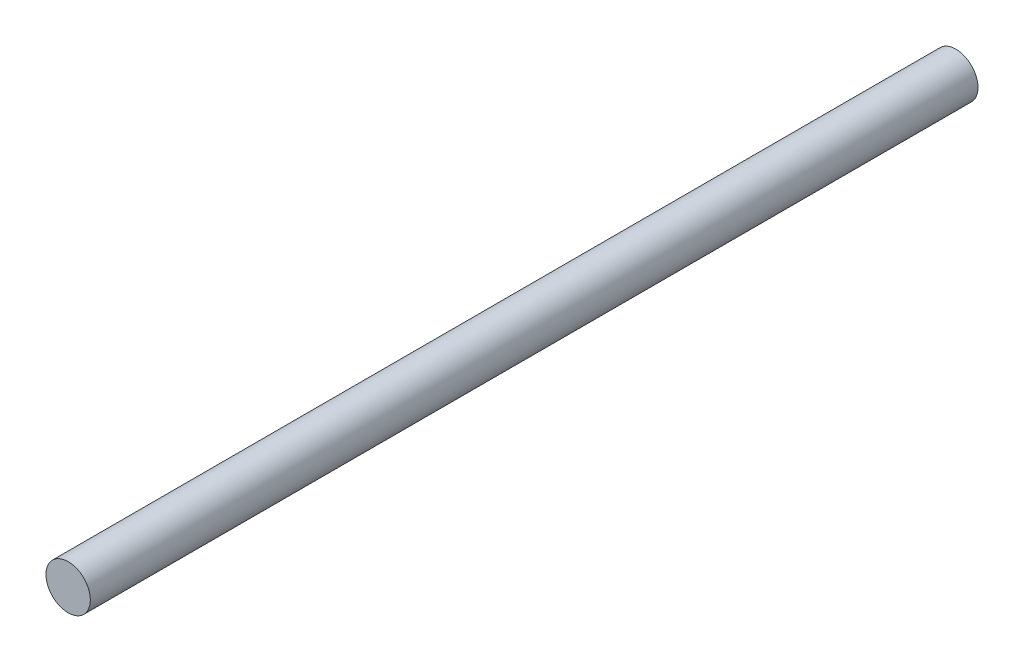
from build123d import *

# Parameters (mm, degrees)
SKETCH_1_R      = 7.5
EXTRUDE_1_DEPTH = 300


with BuildPart() as part:
    # 草图1 → 凸台-拉伸1 (new body)
    with BuildSketch(Plane.XY):
        Circle(SKETCH_1_R)
    extrude(amount=EXTRUDE_1_DEPTH)


solid = part.part
